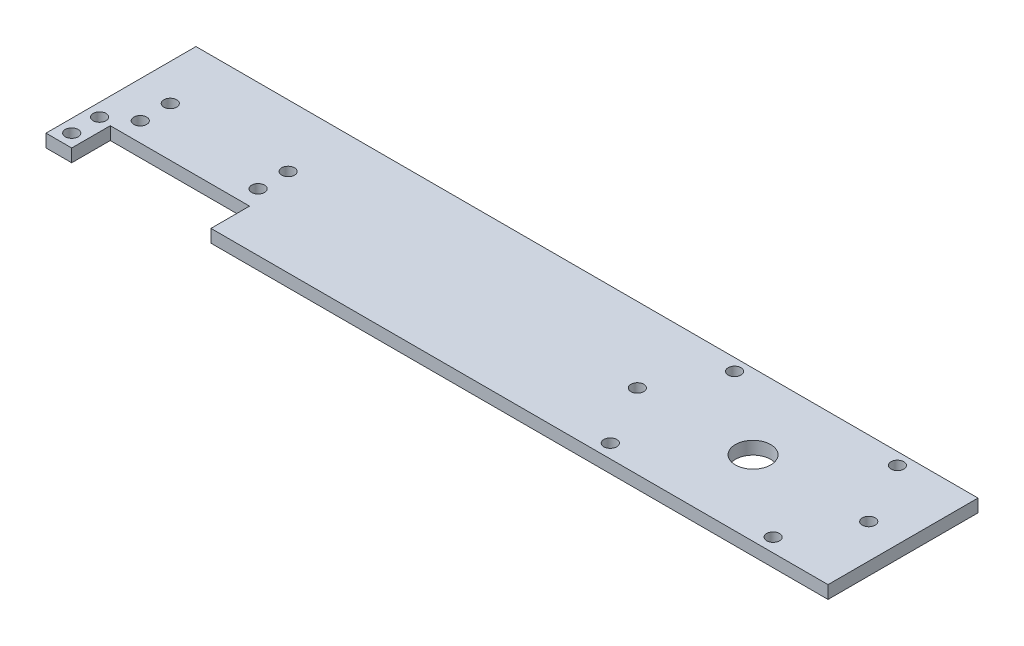
from build123d import *

# Parameters (mm, degrees)
SKETCH1_W           = 182.5
SKETCH1_H           = 35
SKETCH1_R           = 4.125
SKETCH1_R_2         = 1.5
BOSS_EXTRUDE1_DEPTH = 3
CUT_EXTRUDE3_START  = 3.5
SKETCH2_W           = 3
SKETCH2_H           = 9.897866997
SKETCH2_W_2         = 27.5
SKETCH2_W_3         = 2
CUT_EXTRUDE3_DEPTH  = 9
SKETCH3_R           = 1.5
CUT_EXTRUDE7_DEPTH  = 10


with BuildPart() as part:
    # Sketch1 → Boss-Extrude1 (new body)
    with BuildSketch(Plane(origin=(0, 0, 0), x_dir=(1, 0, 0), z_dir=(0, 1, 0))):
        with Locations((-8.75, 5)):
            Rectangle(SKETCH1_W, SKETCH1_H)
        with Locations((47.5, 5)):
            Circle(SKETCH1_R, mode=Mode.SUBTRACT)
        with Locations((74.5, 5)):
            Circle(SKETCH1_R_2, mode=Mode.SUBTRACT)
        with Locations((20.5, 5)):
            Circle(SKETCH1_R_2, mode=Mode.SUBTRACT)
        with Locations((-97, -9.5)):
            Circle(SKETCH1_R_2, mode=Mode.SUBTRACT)
        with Locations((-97, -3)):
            Circle(SKETCH1_R_2, mode=Mode.SUBTRACT)
        with Locations((-91.5, 8)):
            Circle(SKETCH1_R_2, mode=Mode.SUBTRACT)
        with Locations((-64, 8)):
            Circle(SKETCH1_R_2, mode=Mode.SUBTRACT)
        with Locations((-64, 1)):
            Circle(SKETCH1_R_2, mode=Mode.SUBTRACT)
        with Locations((-91.5, 1)):
            Circle(SKETCH1_R_2, mode=Mode.SUBTRACT)
    extrude(amount=BOSS_EXTRUDE1_DEPTH)

    # Sketch2 → Cut-Extrude3 (cut)
    with BuildSketch(Plane.XY.offset(CUT_EXTRUDE3_START)):
        with Locations((-90.5, 1.550857661)):
            Rectangle(SKETCH2_W, SKETCH2_H)
        with Locations((-75.25, 1.550857661)):
            Rectangle(SKETCH2_W_2, SKETCH2_H)
        with Locations((-93, 1.550857661)):
            Rectangle(SKETCH2_W_3, SKETCH2_H)
    extrude(amount=CUT_EXTRUDE3_DEPTH, mode=Mode.SUBTRACT)

    # Sketch3 → Cut-Extrude7 (cut)
    with BuildSketch(Plane(origin=(0, 3, 0), x_dir=(-1, 0, 0), z_dir=(0, -1, 0))):
        with Locations((-66.5, -9.307637977)):
            Circle(SKETCH3_R)
        with Locations((-66.5, 19.692362023)):
            Circle(SKETCH3_R)
        with Locations((-28.5, 19.692362023)):
            Circle(SKETCH3_R)
        with Locations((-28.5, -9.307637977)):
            Circle(SKETCH3_R)
    extrude(amount=CUT_EXTRUDE7_DEPTH, mode=Mode.SUBTRACT)


solid = part.part
